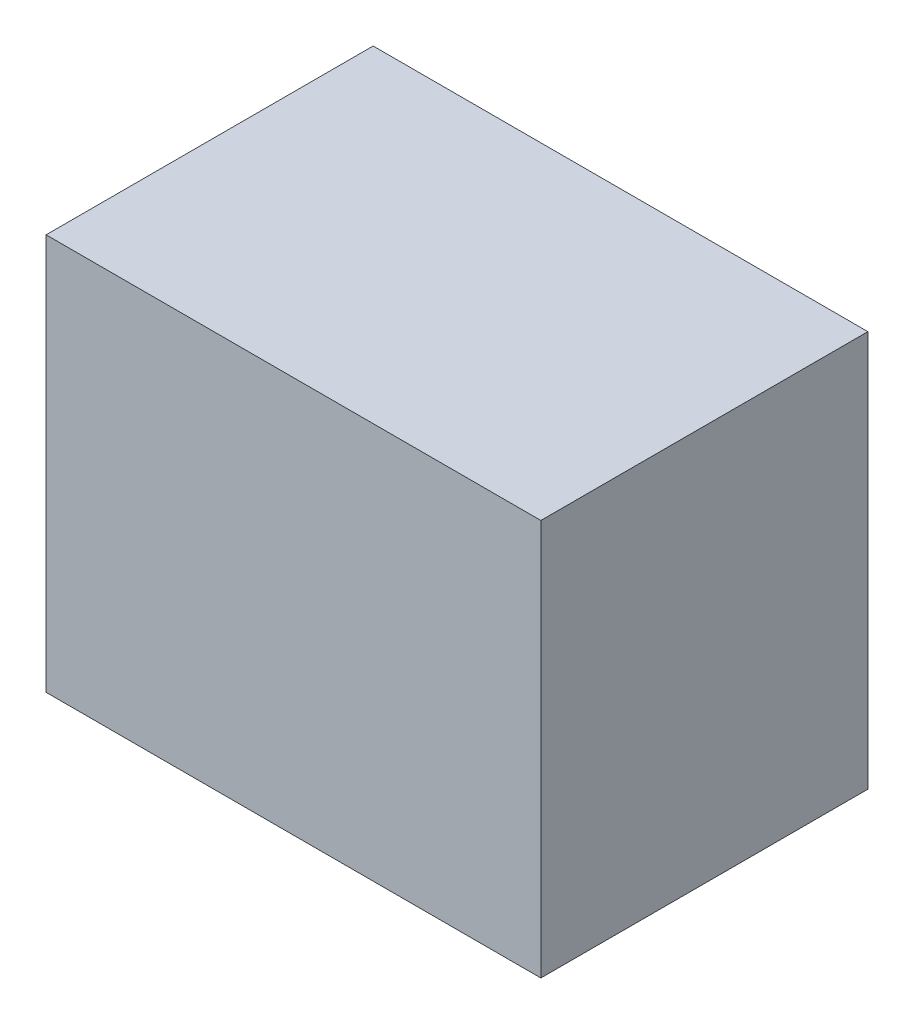
from build123d import *

# Parameters (mm, degrees)
SKETCH1_W           = 500
SKETCH1_H           = 330.508474576
BOSS_EXTRUDE1_DEPTH = 400.455993945


with BuildPart() as part:
    # Sketch1 → Boss-Extrude1 (new body)
    with BuildSketch(Plane(origin=(0, 0, 0), x_dir=(1, 0, 0), z_dir=(0, 1, 0))):
        Rectangle(SKETCH1_W, SKETCH1_H)
    extrude(amount=BOSS_EXTRUDE1_DEPTH)


solid = part.part
